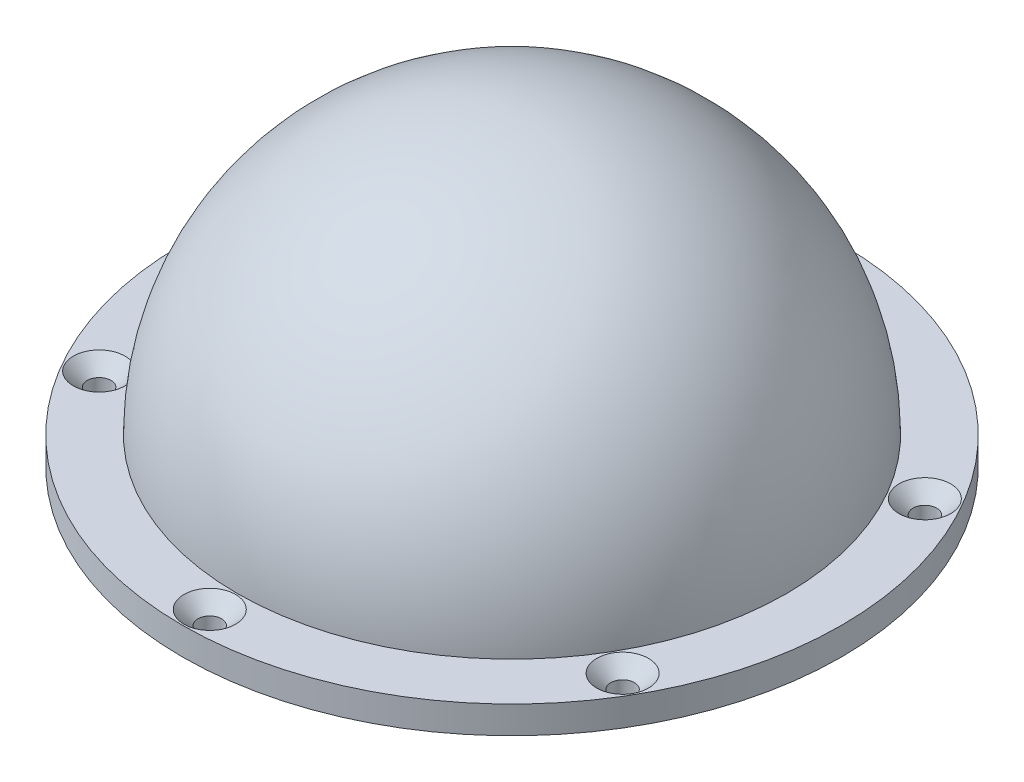
from build123d import *

# Parameters (mm, degrees)
CSK_FOR_M4_COUNTERSUNK_FLAT_HEAD_SCREW1_D           = 4.3
CSK_FOR_M4_COUNTERSUNK_FLAT_HEAD_SCREW1_CSINK_D     = 9.4
CSK_FOR_M4_COUNTERSUNK_FLAT_HEAD_SCREW1_CSINK_ANGLE = 90
PATTERN_CIRCULAR_1_COUNT                            = 6


with BuildPart() as part:
    # Эскиз1 → Повернуть1 (revolve)
    with BuildSketch(Plane.XY):
        with BuildLine():
            Line((0, -5), (60, -5))
            Line((60, -5), (60, 0))
            Line((60, 0), (50, 0))
            ThreePointArc((50, 0), (35.355339059, 35.355339059), (0, 50))
            Line((0, 50), (0, -5))
        make_face()
    revolve(axis=Axis((0, 50, 0), (0, -1, 0)))

    # CSK for M4 Countersunk Flat Head Screw1 (through all)
    with Locations(Plane(origin=(0, 0, -55), x_dir=(1, 0, 0), z_dir=(0, 1, 0))):
        with Locations((0, 0)):
            csk_for_m4_countersunk_flat_head_screw1 = CounterSinkHole(CSK_FOR_M4_COUNTERSUNK_FLAT_HEAD_SCREW1_D / 2, CSK_FOR_M4_COUNTERSUNK_FLAT_HEAD_SCREW1_CSINK_D / 2, counter_sink_angle=CSK_FOR_M4_COUNTERSUNK_FLAT_HEAD_SCREW1_CSINK_ANGLE)

    # Круговой массив1: CSK for M4 Countersunk Flat Head Screw1 ×6 about axis
    pattern_circular_1_axis = Axis((0, 61.603142777, 0), (0, -1, 0))
    for i in range(1, PATTERN_CIRCULAR_1_COUNT):
        add(csk_for_m4_countersunk_flat_head_screw1.rotate(pattern_circular_1_axis, i * 360 / PATTERN_CIRCULAR_1_COUNT), mode=Mode.SUBTRACT)


solid = part.part
